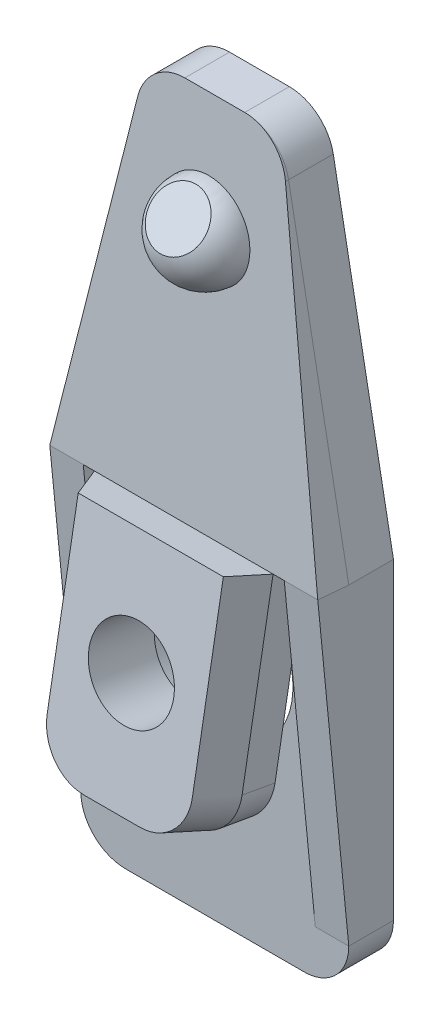
from build123d import *
from build123d.topology import SkipClean

# Parameters (mm, degrees)
BOSS_EXTRUDE1_DEPTH     = 2
FINGERGRIP_DEPTH        = 0.3
BOSS_EXTRUDE2_DEPTH     = 2
REVOLVE1_ANGLE          = 180
CUT_EXTRUDE3_DEPTH      = 24.23093064
CUT_EXTRUDE3_DEPTH_BACK = 24.23093064
BOSS_EXTRUDE6_DEPTH     = 1.5
SKETCH24_R              = 1.9
SCREW_THREADS_DEPTH     = 3
SCREW_HEAD_REACH        = 24.63
SKETCH25_R              = 3.5
WALL1_DEPTH             = 1.5
WALL2_DEPTH             = 1.5


with BuildPart() as part:
    # Sketch1 → Boss-Extrude1 (new body)
    with BuildSketch(Plane.XY):
        with BuildLine():
            Line((-4, -10), (4, -10))
            ThreePointArc((4, -10), (5.414213562, -9.414213562), (6, -8))
            Line((6, -8), (6, 6))
            Line((6, 6), (3.305891799, 20.36857707))
            ThreePointArc((3.305891799, 20.36857707), (2.6174191, 21.539018216), (1.340147425, 22))
            Line((1.340147425, 22), (-1.340147425, 22))
            ThreePointArc((-1.340147425, 22), (-2.6174191, 21.539018216), (-3.305891799, 20.36857707))
            Line((-3.305891799, 20.36857707), (-6, 6))
            Line((-6, 6), (-6, -8))
            ThreePointArc((-6, -8), (-5.414213562, -9.414213562), (-4, -10))
        make_face()
    extrude(amount=BOSS_EXTRUDE1_DEPTH)

    # Sketch8 → FingerGrip (cut)
    with BuildSketch(Plane(origin=(0, 0, 0), x_dir=(-1, 0, 0), z_dir=(0, 0, -1))):
        with BuildLine():
            Line((-4, -4), (4, -4))
            ThreePointArc((4, -4), (4.75, -4.75), (4, -5.5))
            Line((4, -5.5), (-4, -5.5))
            ThreePointArc((-4, -5.5), (-4.75, -4.75), (-4, -4))
        make_face()
        with BuildLine():
            Line((-4, -7), (4, -7))
            ThreePointArc((4, -7), (4.75, -7.75), (4, -8.5))
            Line((4, -8.5), (-4, -8.5))
            ThreePointArc((-4, -8.5), (-4.75, -7.75), (-4, -7))
        make_face()
    extrude(amount=-FINGERGRIP_DEPTH, mode=Mode.SUBTRACT)

    # Sketch2 → Boss-Extrude2 (add)
    with BuildSketch(Plane(origin=(0, 0.340762895, 3.894937707), x_dir=(-1, 0, 0), z_dir=(0, 0.08715574274765835, 0.9961946980917455))):
        with BuildLine():
            Line((6, -5.802856703), (-6, -5.802856703))
            Line((-6, -5.802856703), (-3.305891799, -20.116756999))
            add(Edge.make_bspline(
                [(-3.305891799, -20.116756999), (-3, -21.741971873), (-1.340147425, -21.741971873)],
                knots=[3.326940604, 3.326940604, 3.326940604, 4.71238898, 4.71238898, 4.71238898], degree=2, weights=[1, 0.769509108, 1]))
            Line((-1.340147425, -21.741971873), (1.340147425, -21.741971873))
            add(Edge.make_bspline(
                [(1.340147425, -21.741971873), (3, -21.741971873), (3.305891799, -20.116756999)],
                knots=[4.71238898, 4.71238898, 4.71238898, 6.097837357, 6.097837357, 6.097837357], degree=2, weights=[1, 0.769509108, 1]))
            Line((3.305891799, -20.116756999), (6, -5.802856703))
        make_face()
    extrude(amount=-BOSS_EXTRUDE2_DEPTH)

    # Sketch9 → Revolve1 (revolve)
    with BuildSketch(Plane(origin=(0, 0.340762895, 3.894937707), x_dir=(1, 0, 0), z_dir=(0, 0.08715574274765836, 0.9961946980917457))):
        with BuildLine():
            Line((-2, 16.741971873), (2, 16.741971873))
            ThreePointArc((2, 16.741971873), (0, 14.741971873), (-2, 16.741971873))
        make_face()
    revolve(axis=Axis((0, 17.01902651, 2.435778714), (-1, 0, 0)), revolution_arc=REVOLVE1_ANGLE)

    # Sketch11 → Cut-Extrude3 (cut, two sides)
    with SkipClean():  # the faces are left unmerged after this step: merging them gives an invalid solid
        with BuildSketch(Plane(origin=(0, 0, 0), x_dir=(0, 0, -1), z_dir=(1, 0, 0))) as cut_extrude3_sk:
            Polygon((-4.435231088, 17.065826116), (-2.847274196, 18.976236633), (-5.75514434, 18.976236633), align=None)
        extrude(amount=CUT_EXTRUDE3_DEPTH, mode=Mode.SUBTRACT)
        extrude(cut_extrude3_sk.sketch, amount=-CUT_EXTRUDE3_DEPTH_BACK, mode=Mode.SUBTRACT)

    # Sketch17 → Boss-Extrude6 (add)
    with SkipClean():  # the faces are left unmerged after this step: merging them gives an invalid solid
        with BuildSketch(Plane(origin=(0, 0.764171798, 4.333833624), x_dir=(1, 0, 0), z_dir=(0, 0.1736481776669307, 0.984807753012208))):
            with BuildLine():
                Line((-4, 7.440012187), (-4, -2.559987813))
                ThreePointArc((-4, -2.559987813), (-3.414213562, -3.974201376), (-2, -4.559987813))
                Line((-2, -4.559987813), (2, -4.559987813))
                ThreePointArc((2, -4.559987813), (3.414213562, -3.974201376), (4, -2.559987813))
                Line((4, -2.559987813), (4, 7.440012187))
                Line((4, 7.440012187), (-4, 7.440012187))
            make_face()
        extrude(amount=-BOSS_EXTRUDE6_DEPTH)

    # Sketch23 for ChannelLoft → ChannelLoft section 0
    with SkipClean():  # the faces are left unmerged after this step: merging them gives an invalid solid
        with BuildSketch(Plane(origin=(0, 0.764171798, 4.333833624), x_dir=(1, 0, 0), z_dir=(0, 0.1736481776669307, 0.984807753012208))):
            with BuildLine():
                Line((-4, 5.440012187), (-4, -2.559987813))
                # circular arc as an exact rational Bezier (weights 1, cos(half-angle), 1)
                Bezier((-4, -2.559987813), (-4, -4.559987813), (-2, -4.559987813), weights=[1, 0.707106781, 1])
                Line((-2, -4.559987813), (2, -4.559987813))
                Bezier((2, -4.559987813), (4, -4.559987813), (4, -2.559987813), weights=[1, 0.707106781, 1])
                Line((4, -2.559987813), (4, 5.440012187))
                Line((4, 5.440012187), (-4, 5.440012187))
            make_face()
        # Sketch19 for ChannelLoft → ChannelLoft section 1
        with BuildSketch(Plane(origin=(0, 1.024644064, 5.811045254), x_dir=(1, 0, 0), z_dir=(0, 0.1736481776669307, 0.9848077530122081))):
            with BuildLine():
                Line((-3.25, 5.440012187), (-3.25, -2.559987813))
                Bezier((-3.25, -2.559987813), (-3.25, -4.559987813), (-1.25, -4.559987813), weights=[1, 0.707106781, 1])
                Line((-1.25, -4.559987813), (1.25, -4.559987813))
                Bezier((1.25, -4.559987813), (3.25, -4.559987813), (3.25, -2.559987813), weights=[1, 0.707106781, 1])
                Line((3.25, -2.559987813), (3.25, 5.440012187))
                Line((3.25, 5.440012187), (-3.25, 5.440012187))
            make_face()
        loft()

    # Sketch24 → Screw Threads (cut)
    with SkipClean():  # the faces are left unmerged after this step: merging them gives an invalid solid
        with BuildSketch(Plane(origin=(0, 1.024644064, 5.811045254), x_dir=(1, 0, 0), z_dir=(0, 0.17364817766693072, 0.9848077530122081))):
            with Locations(Location((0, 0.440012187, 0), (0, 0, 270))):
                Circle(SKETCH24_R)
        extrude(amount=-SCREW_THREADS_DEPTH, mode=Mode.SUBTRACT)

    # Screw Head: up to this plane
    with SkipClean():  # the faces are left unmerged after this step: merging them gives an invalid solid
        screw_head_end = Plane(origin=(1.340147425, 20, 0), z_dir=(0, 0, 1))
        # Sketch25 → Screw Head (cut, up to the surface)
        with BuildSketch(Plane(origin=(0, 0.503699531, 2.856621995), x_dir=(-1, 0, 0), z_dir=(0, -0.1736481776669307, -0.9848077530122081)), mode=Mode.PRIVATE) as screw_head_sk1:
            with Locations(Location((0, 0.440012187, 0), (0, 0, 90))):
                Circle(SKETCH25_R)
        screw_head_tool1 = split(extrude(screw_head_sk1.sketch, amount=SCREW_HEAD_REACH, mode=Mode.PRIVATE), bisect_by=screw_head_end, keep=Keep.BOTH, mode=Mode.PRIVATE)
        add(screw_head_tool1.solids().sort_by_distance((0, 0.937027, 2.780215))[0], mode=Mode.SUBTRACT)

    # Sketch26 → Wall1 (add)
    with SkipClean():  # the faces are left unmerged after this step: merging them gives an invalid solid
        with BuildSketch(Plane(origin=(6, 0, 0), x_dir=(0, 0, -1), z_dir=(1, 0, 0))):
            Polygon((-2, 6), (-3.389185421, 6.121537976), (-2, -8), align=None)
        extrude(amount=-WALL1_DEPTH)

    # Sketch27 → Wall2 (add)
    with SkipClean():  # the faces are left unmerged after this step: merging them gives an invalid solid
        with BuildSketch(Plane.ZY.offset(6)):
            Polygon((3.389185421, 6.121537976), (2, 6), (2, -8), align=None)
        extrude(amount=-WALL2_DEPTH)


solid = part.part
